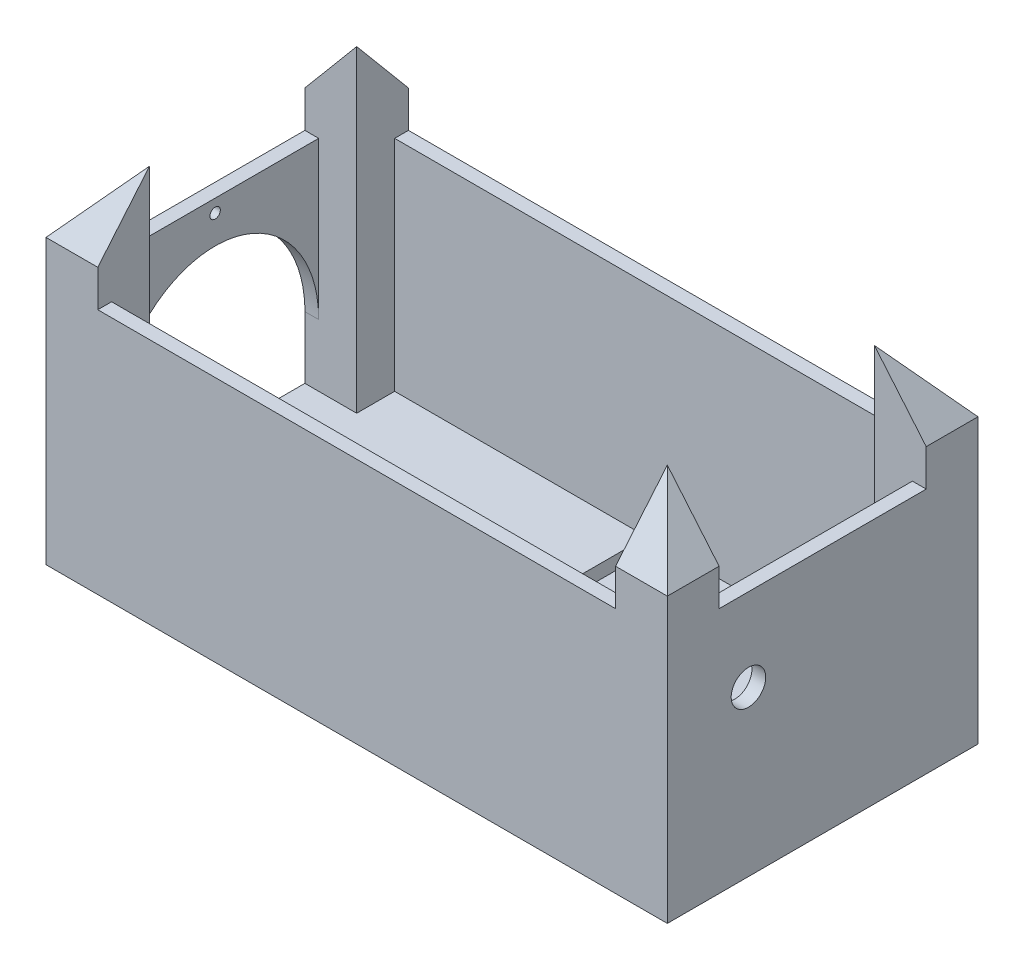
from build123d import *

# Parameters (mm, degrees)
SKETCH1_W                 = 180
SKETCH1_H                 = 90
BOSS_EXTRUDE1_DEPTH       = 71.47
SHELL1_T                  = -4
SKETCH2_R                 = 5
CUT_EXTRUDE1_DEPTH        = 4
SKETCH4_R                 = 2
CUT_EXTRUDE2_DEPTH        = 5
SKETCH7_W                 = 15
SKETCH7_H                 = 15
BOSS_EXTRUDE3_DEPTH       = 98.12
CUT_EXTRUDE4_DEPTH        = 91
CUT_EXTRUDE5_DEPTH        = 181
M3X0_5_TAPPED_HOLE1_D     = 2.5
M3X0_5_TAPPED_HOLE1_DEPTH = 7.5
M3X0_5_TAPPED_HOLE1_TIP   = 0.751075774
SKETCH17_W                = 84
SKETCH17_H                = 39
BOSS_EXTRUDE5_DEPTH       = 4
CUT_EXTRUDE6_DEPTH        = 4
SKETCH18_R                = 1.5
CUT_EXTRUDE7_DEPTH        = 10


with BuildPart() as part:
    # Sketch1 → Boss-Extrude1 (new body)
    with BuildSketch(Plane(origin=(0, 0, 0), x_dir=(1, 0, 0), z_dir=(0, 1, 0))):
        with Locations((90, -45)):
            Rectangle(SKETCH1_W, SKETCH1_H)
    extrude(amount=BOSS_EXTRUDE1_DEPTH)

    # Shell1
    shell1_openings = [part.faces().sort_by_distance(p)[0] for p in [
        (90, 71.47, 45),
    ]]
    offset(amount=SHELL1_T, openings=shell1_openings, kind=Kind.INTERSECTION)

    # Sketch2 → Cut-Extrude1 (cut)
    with BuildSketch(Plane(origin=(180, 0, 0), x_dir=(0, 0, -1), z_dir=(1, 0, 0))):
        with Locations((-66.5, 47.5)):
            Circle(SKETCH2_R)
    extrude(amount=-CUT_EXTRUDE1_DEPTH, mode=Mode.SUBTRACT)

    # Sketch4 → Cut-Extrude2 (cut, through all)
    with BuildSketch(Plane(origin=(0, 4, 0), x_dir=(1, 0, 0), z_dir=(0, 1, 0))):
        with Locations((90, -45)):
            Circle(SKETCH4_R)
    extrude(amount=-CUT_EXTRUDE2_DEPTH, mode=Mode.SUBTRACT)

    # Sketch7 → Boss-Extrude3 (add)
    with BuildSketch(Plane(origin=(0, 4, 0), x_dir=(1, 0, 0), z_dir=(0, 1, 0))):
        with Locations((7.5, -7.5)):
            Rectangle(SKETCH7_W, SKETCH7_H)
        with Locations((172.5, -7.5)):
            Rectangle(SKETCH7_W, SKETCH7_H)
        with Locations((172.5, -82.5)):
            Rectangle(SKETCH7_W, SKETCH7_H)
        with Locations((7.5, -82.5)):
            Rectangle(SKETCH7_W, SKETCH7_H)
    extrude(amount=BOSS_EXTRUDE3_DEPTH)

    # Sketch8 → Cut-Extrude4 (cut, through all)
    with BuildSketch(Plane.XY.offset(90)):
        Polygon((0, 82.12), (90, 189.377823333), (180, 82.12), (180, 229.270433907), (-17.594073619, 229.270433907), (-17.594073619, 82.12), align=None)
    extrude(amount=-CUT_EXTRUDE4_DEPTH, mode=Mode.SUBTRACT)

    # Sketch10 → Cut-Extrude5 (cut, through all)
    with BuildSketch(Plane(origin=(180, 0, 0), x_dir=(0, 0, -1), z_dir=(1, 0, 0))):
        Polygon((-90, 82.12), (-45, 135.748911667), (0, 82.12), (0, 148.632608925), (-124.301287304, 148.632608925), (-124.301287304, 82.12), align=None)
    extrude(amount=-CUT_EXTRUDE5_DEPTH, mode=Mode.SUBTRACT)

    # M3x0.5 Tapped Hole1
    with Locations(Plane(origin=(0, 0, 0), x_dir=(-1, 0, 0), z_dir=(0, -1, 0))):
        with Locations((-172.5, -7.5), (-7.5, -7.5), (-7.5, -82.5), (-172.5, -82.5)):
            Hole(M3X0_5_TAPPED_HOLE1_D / 2, depth=M3X0_5_TAPPED_HOLE1_DEPTH)
            with Locations((0, 0, -(M3X0_5_TAPPED_HOLE1_DEPTH + M3X0_5_TAPPED_HOLE1_TIP / 2))):  # 118° drill point
                Cone(0, M3X0_5_TAPPED_HOLE1_D / 2, M3X0_5_TAPPED_HOLE1_TIP, mode=Mode.SUBTRACT)

    # Sketch17 → Boss-Extrude5 (add)
    with BuildSketch(Plane(origin=(0, 4, 0), x_dir=(1, 0, 0), z_dir=(0, 1, 0))):
        with Locations((46, -23.5)):
            Rectangle(SKETCH17_W, SKETCH17_H)
        with Locations((134, -23.5)):
            Rectangle(SKETCH17_W, SKETCH17_H)
        with Locations((134, -66.5)):
            Rectangle(SKETCH17_W, SKETCH17_H)
        with Locations((46, -66.5)):
            Rectangle(SKETCH17_W, SKETCH17_H)
    extrude(amount=BOSS_EXTRUDE5_DEPTH)

    # Sketch15 → Cut-Extrude6 (cut)
    with BuildSketch(Plane.ZY):
        with BuildLine():
            Line((15, 26), (15, 8))
            Line((15, 8), (75, 8))
            Line((75, 8), (75, 26))
            add(Edge.make_bspline(
                [(75, 26), (75, 59.47), (45, 59.47), (15, 59.47), (15, 26)],
                knots=[1.570796327, 1.570796327, 1.570796327, 3.141592654, 3.141592654, 4.71238898, 4.71238898, 4.71238898], degree=2, weights=[1, 0.707106781, 1, 0.707106781, 1]))
        make_face()
    extrude(amount=-CUT_EXTRUDE6_DEPTH, mode=Mode.SUBTRACT)

    # Sketch18 → Cut-Extrude7 (cut)
    with BuildSketch(Plane.ZY):
        with Locations((82.75, 7.75)):
            Circle(SKETCH18_R)
        with Locations((45, 67.72)):
            Circle(SKETCH18_R)
        with Locations((7.25, 7.75)):
            Circle(SKETCH18_R)
    extrude(amount=-CUT_EXTRUDE7_DEPTH, mode=Mode.SUBTRACT)


solid = part.part
